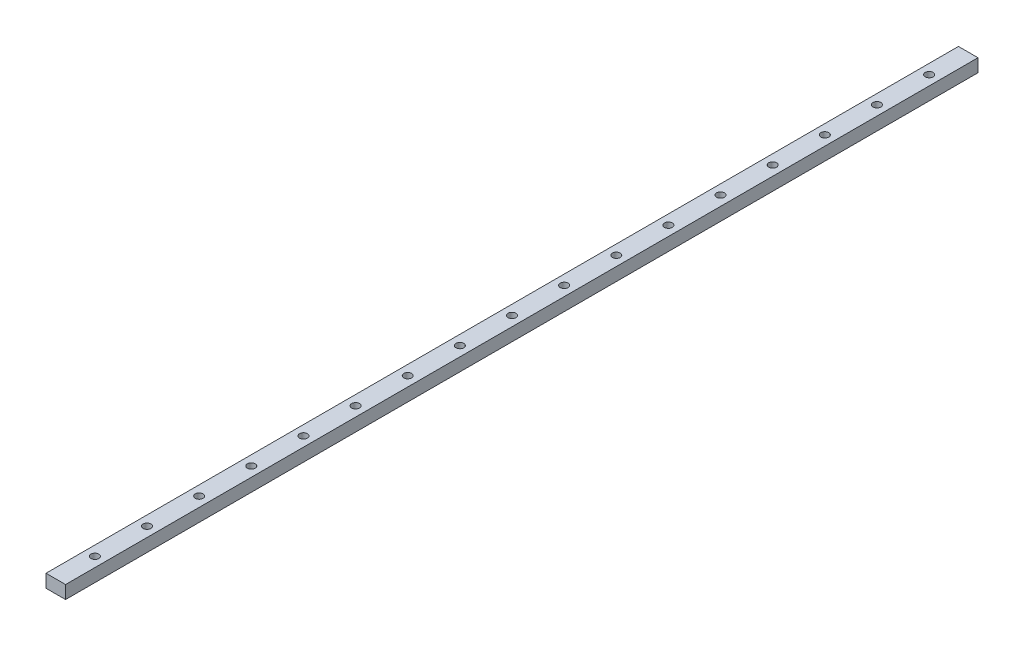
from build123d import *

# Parameters (mm, degrees)
SKETCH1_W                      = 15
SKETCH1_H                      = 10
BOSS_EXTRUDE1_DEPTH            = 700
CBORE_FOR_M3_SHCS1_D           = 3.5
CBORE_FOR_M3_SHCS1_CBORE_D     = 6
CBORE_FOR_M3_SHCS1_CBORE_DEPTH = 4.5
LPATTERN1_COUNT                = 17
LPATTERN1_PITCH                = 40


with BuildPart() as part:
    # Sketch1 → Boss-Extrude1 (new body)
    with BuildSketch(Plane.XY):
        with Locations((7.5, 5)):
            Rectangle(SKETCH1_W, SKETCH1_H)
    extrude(amount=BOSS_EXTRUDE1_DEPTH)

    # CBORE for M3 SHCS1 (through all)
    with Locations(Plane(origin=(0, 10, 0), x_dir=(1, 0, 0), z_dir=(0, 1, 0))):
        with Locations((7.5, -670)):
            cbore_for_m3_shcs1 = CounterBoreHole(CBORE_FOR_M3_SHCS1_D / 2, CBORE_FOR_M3_SHCS1_CBORE_D / 2, CBORE_FOR_M3_SHCS1_CBORE_DEPTH)

    # LPattern1: CBORE for M3 SHCS1 ×17
    with Locations(*[(0, 0, -i * LPATTERN1_PITCH) for i in range(1, LPATTERN1_COUNT)]):
        add(cbore_for_m3_shcs1, mode=Mode.SUBTRACT)


solid = part.part
